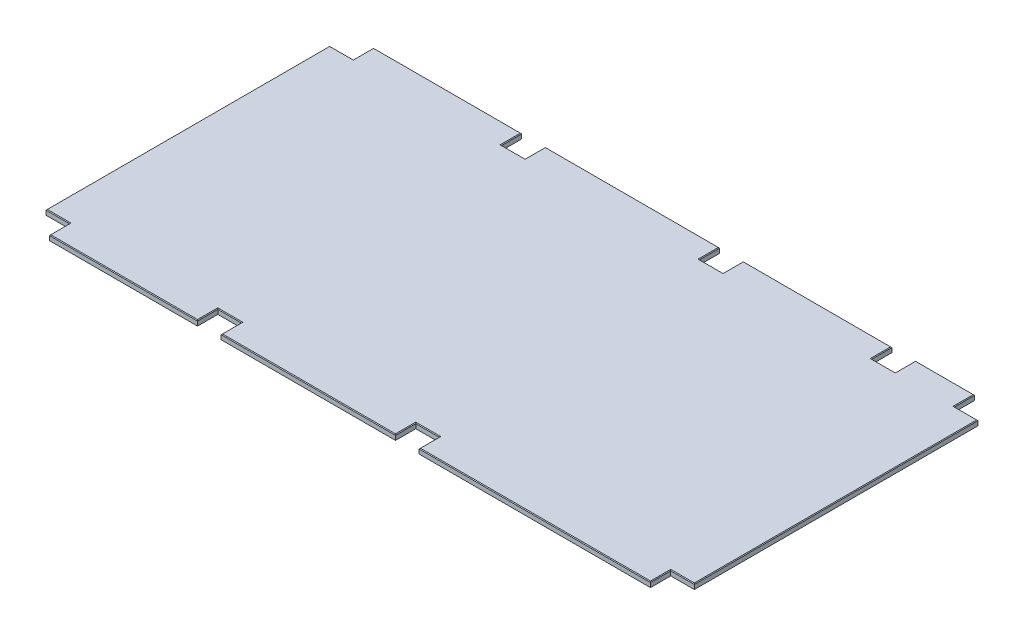
from build123d import *

# Parameters (mm, degrees)
SKETCH1_W           = 2438.4
SKETCH1_H           = 1219.2
BOSS_EXTRUDE1_DEPTH = 9.525
SKETCH2_W           = 88.9
SKETCH2_H           = 76.2
CUT_EXTRUDE1_DEPTH  = 20.05
CHAMFER1_SIZE       = 2.54


with BuildPart() as part:
    # Sketch1 → Boss-Extrude1 (new body, symmetric)
    with BuildSketch(Plane(origin=(0, 0, 0), x_dir=(1, 0, 0), z_dir=(0, 1, 0))):
        with Locations((1219.2, 609.6)):
            Rectangle(SKETCH1_W, SKETCH1_H)
    extrude(amount=BOSS_EXTRUDE1_DEPTH, both=True)

    # Sketch2 → Cut-Extrude1 (cut, through all)
    with BuildSketch(Plane(origin=(0, 9.525, 0), x_dir=(1, 0, 0), z_dir=(0, 1, 0))):
        with Locations((44.45, 1181.1)):
            Rectangle(SKETCH2_W, SKETCH2_H)
        with Locations((690.5625, 1181.1)):
            Rectangle(SKETCH2_W, SKETCH2_H)
        with Locations((1435.1127, 1181.1)):
            Rectangle(SKETCH2_W, SKETCH2_H)
        with Locations((2082.8, 1181.1)):
            Rectangle(SKETCH2_W, SKETCH2_H)
        with Locations((2393.95, 1181.1)):
            Rectangle(SKETCH2_W, SKETCH2_H)
        with Locations((1435.1127, 38.1)):
            Rectangle(SKETCH2_W, SKETCH2_H)
        with Locations((690.5625, 38.1)):
            Rectangle(SKETCH2_W, SKETCH2_H)
        with Locations((2393.95, 38.1)):
            Rectangle(SKETCH2_W, SKETCH2_H)
        with Locations((44.45, 38.1)):
            Rectangle(SKETCH2_W, SKETCH2_H)
    extrude(amount=-CUT_EXTRUDE1_DEPTH, mode=Mode.SUBTRACT)

    # Chamfer1
    chamfer1_edges = [part.edges().sort_by_distance(p)[0] for p in [
        (646.1125, 9.525, -1181.1),
        (690.5625, 9.525, -1143),
        (735.0125, 9.525, -1181.1),
        (44.45, 9.525, -1143),
        (88.9, 9.525, -1181.1),
        (0, 9.525, -609.6),
        (367.50625, 9.525, 0),
        (1062.8376, 9.525, 0),
        (1914.53135, 9.525, 0),
        (2438.4, 9.525, -609.6),
        (2238.375, 9.525, -1219.2),
        (1758.95635, 9.525, -1219.2),
        (1062.8376, 9.525, -1219.2),
        (367.50625, 9.525, -1219.2),
        (1479.5627, 9.525, -38.1),
        (1435.1127, 9.525, -76.2),
        (1390.6627, 9.525, -38.1),
        (735.0125, 9.525, -38.1),
        (690.5625, 9.525, -76.2),
        (646.1125, 9.525, -38.1),
        (2393.95, 9.525, -76.2),
        (2349.5, 9.525, -38.1),
        (88.9, 9.525, -38.1),
        (44.45, 9.525, -76.2),
        (2349.5, 9.525, -1181.1),
        (2393.95, 9.525, -1143),
        (2038.35, 9.525, -1181.1),
        (2082.8, 9.525, -1143),
        (2127.25, 9.525, -1181.1),
        (1479.5627, 9.525, -1181.1),
        (1390.6627, 9.525, -1181.1),
        (1435.1127, 9.525, -1143),
    ]]
    chamfer(chamfer1_edges, length=CHAMFER1_SIZE)


solid = part.part
